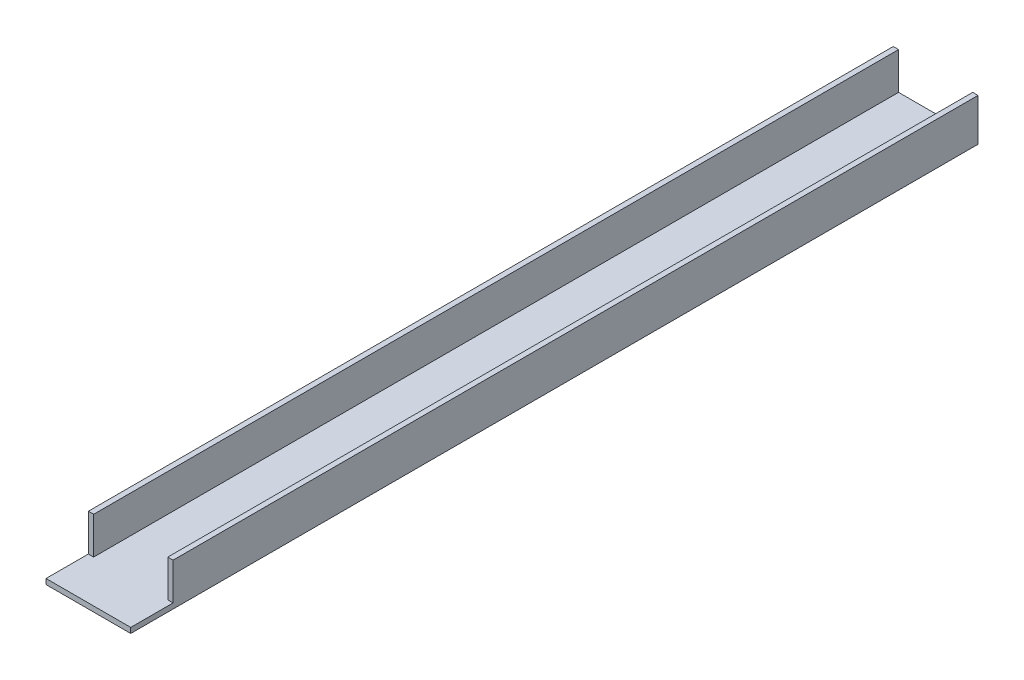
from build123d import *

# Parameters (mm, degrees)
BOSS_EXTRUDE1_DEPTH = 508
SKETCH2_W           = 50.8
SKETCH2_H           = 25.4
CUT_EXTRUDE1_DEPTH  = 22.225


with BuildPart() as part:
    # Sketch1 → Boss-Extrude1 (new body)
    with BuildSketch(Plane.XY):
        Polygon((3.175, 3.175), (3.175, 25.4), (0, 25.4), (0, 0), (50.8, 0), (50.8, 25.4), (47.625, 25.4), (47.625, 3.175), align=None)
    extrude(amount=BOSS_EXTRUDE1_DEPTH)

    # Sketch2 → Cut-Extrude1 (cut)
    with BuildSketch(Plane(origin=(0, 25.4, 0), x_dir=(1, 0, 0), z_dir=(0, 1, 0))):
        with Locations((25.4, -495.3)):
            Rectangle(SKETCH2_W, SKETCH2_H)
    extrude(amount=-CUT_EXTRUDE1_DEPTH, mode=Mode.SUBTRACT)


solid = part.part
